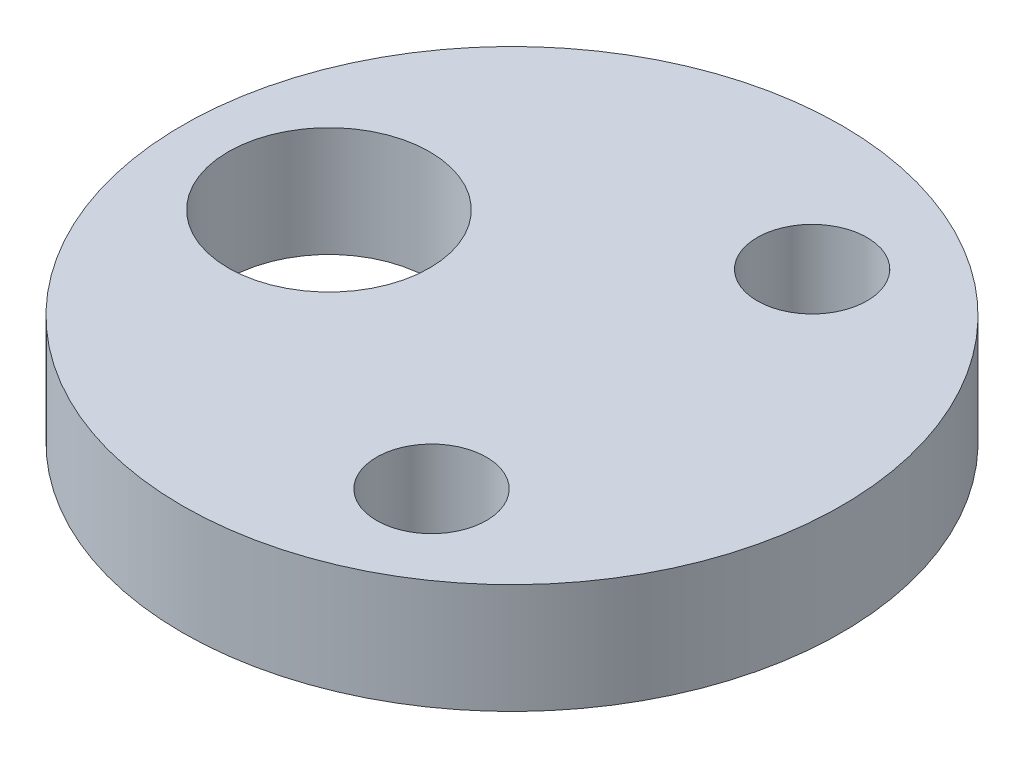
from build123d import *

# Parameters (mm, degrees)
SKETCH1_R           = 9
SKETCH1_R_2         = 1.5
SKETCH1_R_3         = 2.75
BOSS_EXTRUDE1_DEPTH = 3


with BuildPart() as part:
    # Sketch1 → Boss-Extrude1 (new body)
    with BuildSketch(Plane(origin=(0, 0, 0), x_dir=(1, 0, 0), z_dir=(0, 1, 0))):
        Circle(SKETCH1_R)
        with Locations((2.999131959, -5.19665349)):
            Circle(SKETCH1_R_2, mode=Mode.SUBTRACT)
        with Locations((3.000867957, 5.195651211)):
            Circle(SKETCH1_R_2, mode=Mode.SUBTRACT)
        with Locations((-5, 0.000835232)):
            Circle(SKETCH1_R_3, mode=Mode.SUBTRACT)
    extrude(amount=BOSS_EXTRUDE1_DEPTH)


solid = part.part
